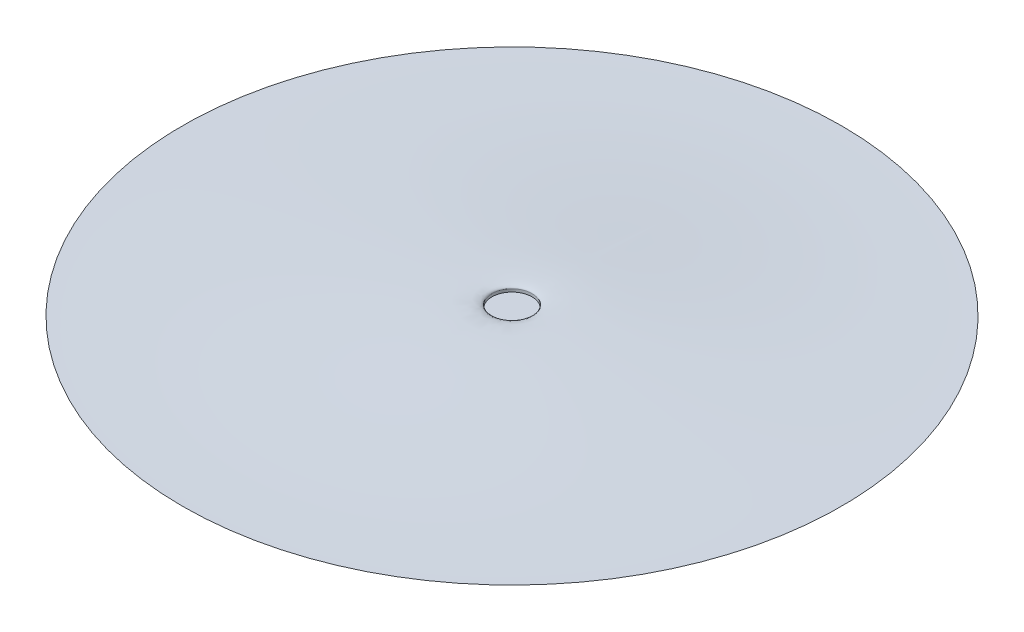
from build123d import *


with BuildPart() as part:
    # Sketch2 → Revolve1 (revolve)
    with BuildSketch(Plane(origin=(0, 0, 0), x_dir=(0, 0, -1), z_dir=(1, 0, 0))):
        with BuildLine():
            Line((7.702837196, 3.627025238), (7.702837196, 2.543661894))
            Line((7.702837196, 2.543661894), (0, 2.543661894))
            Line((0, 2.543661894), (0, -2.543661894))
            Line((0, -2.543661894), (7.702837196, -2.543661894))
            Line((7.702837196, -2.543661894), (7.702837196, -4.739723491))
            add(Edge.make_bspline(
                [(7.702837196, -4.739723491), (7.702837196, -10.070621758), (63.5, 0), (127, 0)],
                knots=[0, 0, 0, 0, 1, 1, 1, 1], degree=3))
            add(Edge.make_bspline(
                [(7.702837196, 3.627025238), (7.702837196, 8.15926534), (63.5, 0), (127, 0)],
                knots=[0, 0, 0, 0, 1, 1, 1, 1], degree=3))
        make_face()
    revolve(axis=Axis((0, -2.543661894, 0), (0, 1, 0)))


solid = part.part
